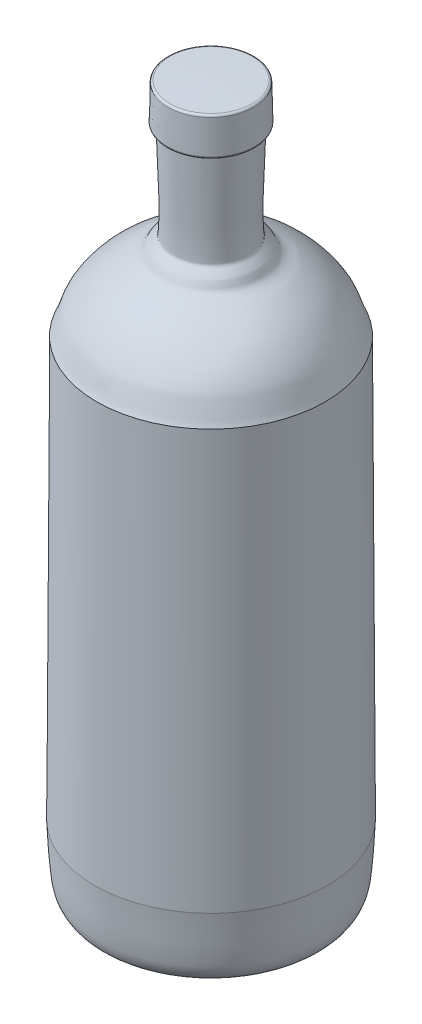
from build123d import *


with BuildPart() as part:
    # Skizze1 → Rotation1 (revolve)
    with BuildSketch(Plane.XY, mode=Mode.PRIVATE) as rotation1_sk:
        with BuildLine():
            Line((118.802046146, 1022.196696021), (176.964475157, 1024.103660907))
            Line((176.964475157, 1024.103660907), (177, 1023.888109373))
            Line((177, 1023.888109373), (177, 0.348553443))
            add(Edge.make_bspline(
                [(177, 0.348553443), (155.865875344, -0.049607015), (134.786920125, 0.63740998), (114, 4), (102.48360535, 5.862946193), (64.153109498, 4.609112023), (44, 16), (37.629076517, 19.600956751), (29.895595043, 21.560449952), (25, 27), (20.402979586, 32.10780046), (18.004259572, 39.201935207), (17, 46), (13.629938224, 68.812725865), (13.666666667, 92), (12, 115)],
                knots=[3.482218919, 3.482218919, 3.482218919, 3.482218919, 4, 4, 4, 5, 5, 5, 6, 6, 6, 7, 7, 7, 8, 8, 8, 8], degree=3))
            Line((12, 115), (14.998694181, 707.741883078))
            add(Edge.make_bspline(
                [(14.998694181, 707.741883078), (20.981370035, 719.493328883), (22.735095514, 733.183933146), (29.26673881, 744.639347794), (35.739688358, 755.99182338), (44.18359103, 766.291093776), (53.490993869, 775.464426331), (62.465440762, 784.309599068), (73.152898477, 791.286271073), (83.657055799, 798.246188942), (90.620513231, 802.860085166), (99.269721474, 804.807300601), (105.743529772, 810.086276249), (109.332407544, 813.012775998), (110.025107715, 818.350781682), (112.830398448, 822.035179645), (116.117568409, 826.352465608), (123.574773092, 828.539604738), (123.91716187, 833.955065417), (126.673177858, 877.546144248), (122.550765948, 921.300609512), (121.867567987, 964.97338156)],
                knots=[0, 0, 0, 0, 1, 1, 1, 2, 2, 2, 3, 3, 3, 4, 4, 4, 5, 5, 5, 6, 6, 6, 7, 7, 7, 7], degree=3))
            ThreePointArc((121.867567987, 964.97338156), (121.292270479, 966.686317901), (119.837491405, 967.758108914))
            Line((119.837491405, 967.758108914), (116.86842359, 968.771936948))
            ThreePointArc((116.86842359, 968.771936948), (115.378415373, 969.893093626), (114.838602637, 971.677951881))
            Line((114.838602637, 971.677951881), (115.901101463, 1019.265272556))
            ThreePointArc((115.901101463, 1019.265272556), (116.767977156, 1021.308513129), (118.802046146, 1022.196696021))
        make_face()
    revolve(rotation1_sk.sketch.rotate(Axis((177, 1120.97176066, 0), (0, -1, 0)), 270), axis=Axis((177, 1120.97176066, 0), (0, -1, 0)))  # turned: the seam where the file's is


solid = part.part
